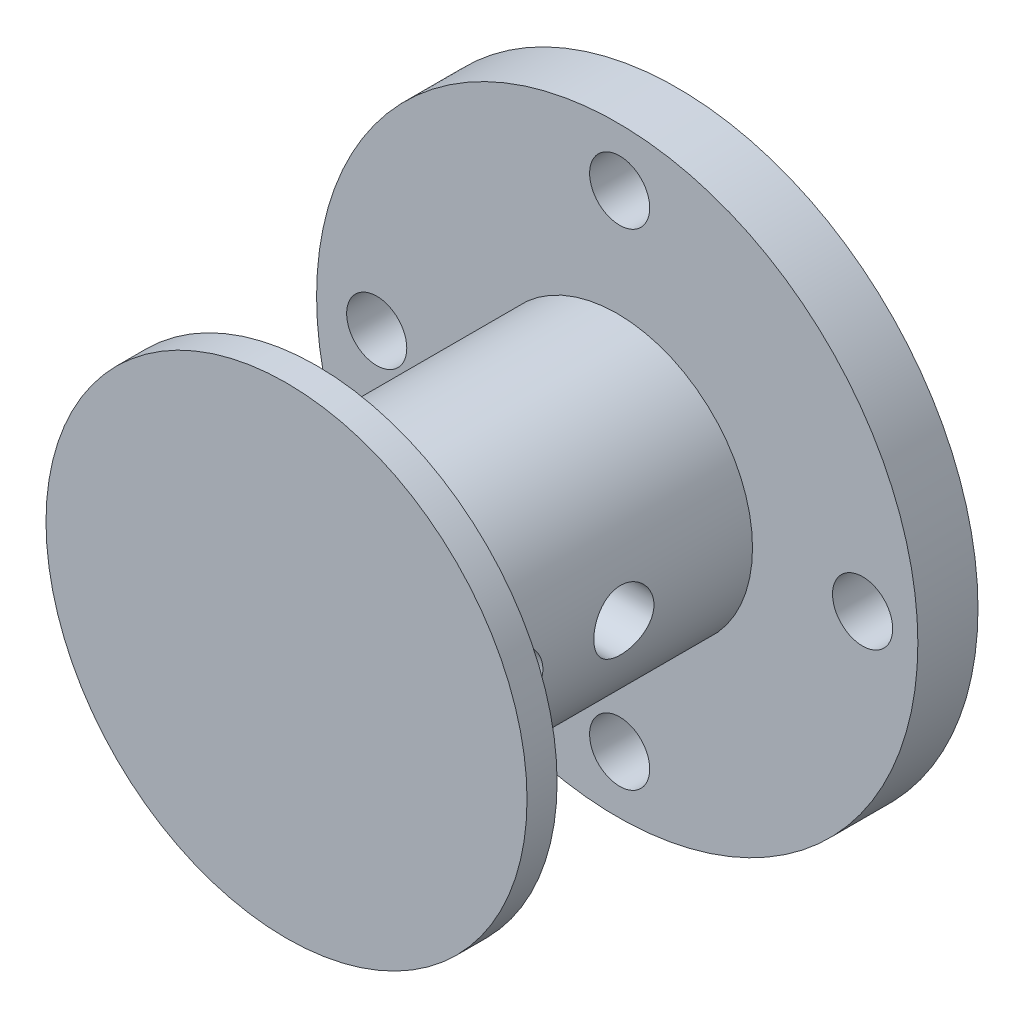
from build123d import *

# Parameters (mm, degrees)
SKIZZE1_R                            = 10
AUFSATZ_LINEAR_AUSTRAGEN1_DEPTH      = 2
SKIZZE4_R                            = 1
SCHNITT_LINEAR_AUSTRAGEN1_DEPTH      = 2
KREISMUSTER1_COUNT                   = 4
SKIZZE5_R                            = 4.5
AUFSATZ_LINEAR_AUSTRAGEN2_DEPTH      = 10
SKIZZE6_R                            = 8
AUFSATZ_LINEAR_AUSTRAGEN3_DEPTH      = 1
SKIZZE7_R                            = 1
SCHNITT_LINEAR_AUSTRAGEN2_DEPTH      = 5
SCHNITT_LINEAR_AUSTRAGEN2_DEPTH_BACK = 5


with BuildPart() as part:
    # Skizze1 → Aufsatz-Linear austragen1 (new body)
    with BuildSketch(Plane.XY):
        Circle(SKIZZE1_R)
    extrude(amount=AUFSATZ_LINEAR_AUSTRAGEN1_DEPTH)

    # Skizze4 → Schnitt-Linear austragen1 (cut)
    with BuildSketch(Plane.XY.offset(2)):
        with Locations((-8, 0)):
            Circle(SKIZZE4_R)
    schnitt_linear_austragen1 = extrude(amount=-SCHNITT_LINEAR_AUSTRAGEN1_DEPTH, mode=Mode.SUBTRACT)

    # Kreismuster1: Schnitt-Linear austragen1 ×4 about axis
    kreismuster1_axis = Axis((0.080808081, 0, 0), (0, 0, 1))
    for i in range(1, KREISMUSTER1_COUNT):
        add(schnitt_linear_austragen1.rotate(kreismuster1_axis, i * 360 / KREISMUSTER1_COUNT), mode=Mode.SUBTRACT)

    # Skizze5 → Aufsatz-Linear austragen2 (add)
    with BuildSketch(Plane.XY.offset(2)):
        Circle(SKIZZE5_R)
    extrude(amount=AUFSATZ_LINEAR_AUSTRAGEN2_DEPTH)

    # Skizze6 → Aufsatz-Linear austragen3 (add)
    with BuildSketch(Plane.XY.offset(12)):
        Circle(SKIZZE6_R)
    extrude(amount=AUFSATZ_LINEAR_AUSTRAGEN3_DEPTH)

    # Skizze7 → Schnitt-Linear austragen2 (cut, two sides)
    with BuildSketch(Plane(origin=(0, 0, 0), x_dir=(0, 0, -1), z_dir=(1, 0, 0))) as schnitt_linear_austragen2_sk:
        with Locations((-9.972447251, 0)):
            Circle(SKIZZE7_R)
        with Locations((-6.278379976, 0)):
            Circle(SKIZZE7_R)
    extrude(amount=SCHNITT_LINEAR_AUSTRAGEN2_DEPTH, mode=Mode.SUBTRACT)
    extrude(schnitt_linear_austragen2_sk.sketch, amount=-SCHNITT_LINEAR_AUSTRAGEN2_DEPTH_BACK, mode=Mode.SUBTRACT)


solid = part.part
